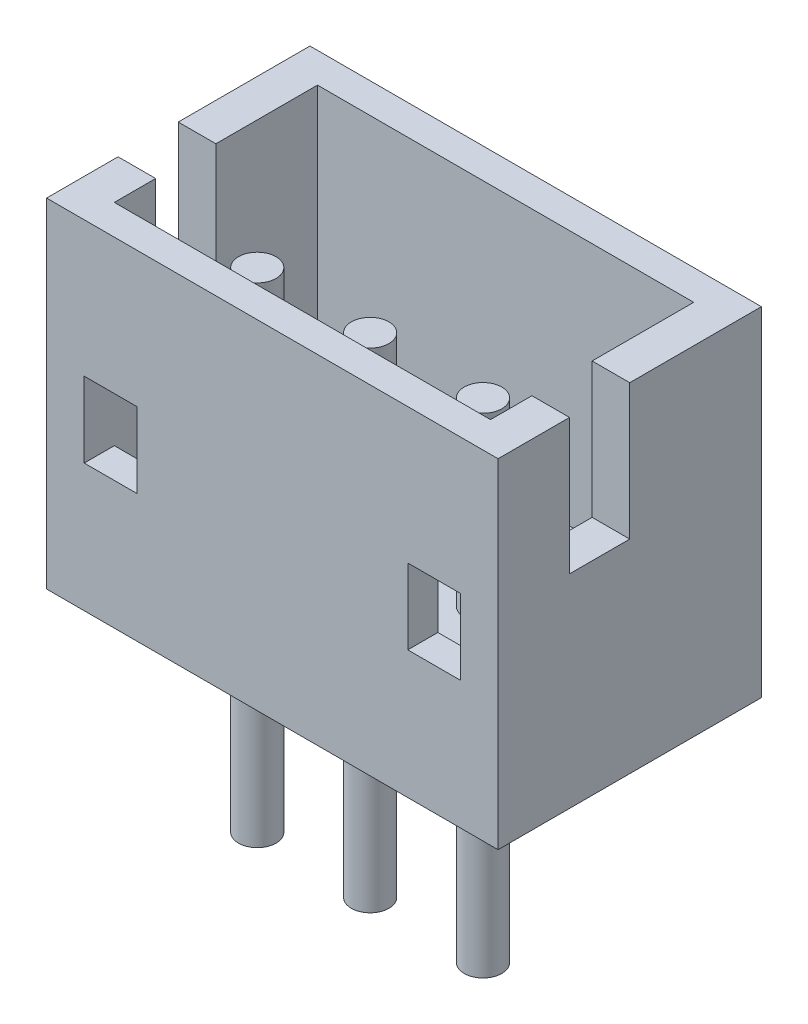
from build123d import *

# Parameters (mm, degrees)
SKETCH1_W           = 3.6
SKETCH1_H           = 2.8
BOSS_EXTRUDE1_DEPTH = 0.4
SKETCH2_W           = 0.4
SKETCH2_H           = 1.8
BOSS_EXTRUDE2_DEPTH = 0.7
SKETCH3_W           = 0.4
SKETCH3_H           = 1.8
BOSS_EXTRUDE3_DEPTH = 0.7
SKETCH4_W           = 3.1
SKETCH4_H           = 2.8
BOSS_EXTRUDE4_DEPTH = 0.5
SKETCH5_W           = 5.5
SKETCH5_H           = 3.1
BOSS_EXTRUDE5_DEPTH = 1.7
SKETCH6_W           = 3.1
SKETCH6_H           = 4.5
BOSS_EXTRUDE6_DEPTH = 0.5
SKETCH7_W           = 6
SKETCH7_H           = 4.5
BOSS_EXTRUDE7_DEPTH = 0.4
SKETCH8_W           = 5
SKETCH8_H           = 2.7
CUT_EXTRUDE1_DEPTH  = 0.6
BOSS_EXTRUDE8_DEPTH = 5
CUT_EXTRUDE2_REACH  = 8
SKETCH10_W          = 0.8
SKETCH10_H          = 1.8
SKETCH11_W          = 0.8
SKETCH11_H          = 1.8
CUT_EXTRUDE3_DEPTH  = 7
SKETCH12_W          = 0.25
SKETCH12_H          = 2.7
SKETCH13_W          = 0.25
SKETCH13_H          = 2.7
SKETCH14_W          = 0.25
SKETCH14_H          = 2.7
SKETCH15_W          = 0.25
SKETCH15_H          = 2.4
SKETCH16_W          = 0.25
SKETCH16_H          = 2.4
SKETCH17_W          = 0.25
SKETCH17_H          = 2.4


with BuildPart() as part:
    # Sketch1 → Boss-Extrude1 (new body)
    with BuildSketch(Plane.XY):
        with Locations((0, 3.1)):
            Rectangle(SKETCH1_W, SKETCH1_H)
    extrude(amount=-BOSS_EXTRUDE1_DEPTH)

    # Sketch2 → Boss-Extrude2 (add)
    with BuildSketch(Plane.ZY.offset(1.8)):
        with Locations((-0.2, 3.6)):
            Rectangle(SKETCH2_W, SKETCH2_H)
    extrude(amount=BOSS_EXTRUDE2_DEPTH)

    # Sketch3 → Boss-Extrude3 (add)
    with BuildSketch(Plane(origin=(1.8, 0, 0), x_dir=(0, 0, -1), z_dir=(1, 0, 0))):
        with Locations((0.2, 3.6)):
            Rectangle(SKETCH3_W, SKETCH3_H)
    extrude(amount=BOSS_EXTRUDE3_DEPTH)

    # Sketch4 → Boss-Extrude4 (add)
    with BuildSketch(Plane(origin=(2.5, 0, 0), x_dir=(0, 0, -1), z_dir=(1, 0, 0))):
        with Locations((1.55, 3.1)):
            Rectangle(SKETCH4_W, SKETCH4_H)
    extrude(amount=BOSS_EXTRUDE4_DEPTH)

    # Sketch5 → Boss-Extrude5 (add)
    with BuildSketch(Plane.XZ.offset(-1.7)):
        with Locations((0.25, -1.55)):
            Rectangle(SKETCH5_W, SKETCH5_H)
    extrude(amount=BOSS_EXTRUDE5_DEPTH)

    # Sketch6 → Boss-Extrude6 (add)
    with BuildSketch(Plane.ZY.offset(2.5)):
        with Locations((-1.55, 2.25)):
            Rectangle(SKETCH6_W, SKETCH6_H)
    extrude(amount=BOSS_EXTRUDE6_DEPTH)

    # Sketch7 → Boss-Extrude7 (add)
    with BuildSketch(Plane(origin=(0, 0, -3.1), x_dir=(-1, 0, 0), z_dir=(0, 0, -1))):
        with Locations((0, 2.25)):
            Rectangle(SKETCH7_W, SKETCH7_H)
    extrude(amount=BOSS_EXTRUDE7_DEPTH)

    # Sketch8 → Cut-Extrude1 (cut)
    with BuildSketch(Plane(origin=(0, 1.7, 0), x_dir=(-1, 0, 0), z_dir=(0, 1, 0))):
        with Locations((0, -1.75)):
            Rectangle(SKETCH8_W, SKETCH8_H)
    extrude(amount=-CUT_EXTRUDE1_DEPTH, mode=Mode.SUBTRACT)

    # Sketch9 → Boss-Extrude8 (add)
    with BuildSketch(Plane.ZY.offset(-2.5)):
        Polygon((-0.4, 1.4), (-0.4, 1.1), (-2.05, 1.1), (-1.75, 1.4), align=None)
    extrude(amount=BOSS_EXTRUDE8_DEPTH)

    # Sketch10 → Cut-Extrude2 (cut, up to next)
    with BuildSketch(Plane(origin=(3, 0, 0), x_dir=(0, 0, -1), z_dir=(1, 0, 0)), mode=Mode.PRIVATE) as cut_extrude2_sk1:
        with Locations((1.35, 3.6)):
            Rectangle(SKETCH10_W, SKETCH10_H)
    cut_extrude2_tool1 = extrude(cut_extrude2_sk1.sketch, amount=-CUT_EXTRUDE2_REACH, mode=Mode.PRIVATE) & part.part
    add(cut_extrude2_tool1.solids().sort_by_distance((3, 3.6, -1.35))[0], mode=Mode.SUBTRACT)

    # Sketch11 → Cut-Extrude3 (cut, through all)
    with BuildSketch(Plane.ZY.offset(3)):
        with Locations((-1.35, 3.6)):
            Rectangle(SKETCH11_W, SKETCH11_H)
    extrude(amount=-CUT_EXTRUDE3_DEPTH, mode=Mode.SUBTRACT)

    # Sketch12 → Revolve1 (revolve)
    with BuildSketch(Plane(origin=(0, 0, -1.3), x_dir=(-1, 0, 0), z_dir=(0, 0, -1))):
        with Locations((1.375, -1.35)):
            Rectangle(SKETCH12_W, SKETCH12_H)
    revolve(axis=Axis((-1.5, -2.7, -1.3), (0, 1, 0)))

    # Sketch13 → Revolve2 (revolve)
    with BuildSketch(Plane(origin=(0, 0, -1.3), x_dir=(-1, 0, 0), z_dir=(0, 0, -1))):
        with Locations((-0.125, -1.35)):
            Rectangle(SKETCH13_W, SKETCH13_H)
    revolve(axis=Axis((0, -2.7, -1.3), (0, 1, 0)))

    # Sketch14 → Revolve3 (revolve)
    with BuildSketch(Plane(origin=(0, 0, -1.3), x_dir=(-1, 0, 0), z_dir=(0, 0, -1))):
        with Locations((-1.625, -1.35)):
            Rectangle(SKETCH14_W, SKETCH14_H)
    revolve(axis=Axis((1.5, -2.7, -1.3), (0, 1, 0)))

    # Sketch15 → Revolve4 (revolve)
    with BuildSketch(Plane(origin=(0, 0, -1.3), x_dir=(-1, 0, 0), z_dir=(0, 0, -1))):
        with Locations((-1.625, 2.6)):
            Rectangle(SKETCH15_W, SKETCH15_H)
    revolve(axis=Axis((1.5, 1.4, -1.3), (0, 1, 0)))

    # Sketch16 → Revolve5 (revolve)
    with BuildSketch(Plane(origin=(0, 0, -1.3), x_dir=(-1, 0, 0), z_dir=(0, 0, -1))):
        with Locations((-0.125, 2.6)):
            Rectangle(SKETCH16_W, SKETCH16_H)
    revolve(axis=Axis((0, 1.4, -1.3), (0, 1, 0)))

    # Sketch17 → Revolve6 (revolve)
    with BuildSketch(Plane(origin=(0, 0, -1.3), x_dir=(-1, 0, 0), z_dir=(0, 0, -1))):
        with Locations((1.375, 2.6)):
            Rectangle(SKETCH17_W, SKETCH17_H)
    revolve(axis=Axis((-1.5, 1.4, -1.3), (0, 1, 0)))


solid = part.part
